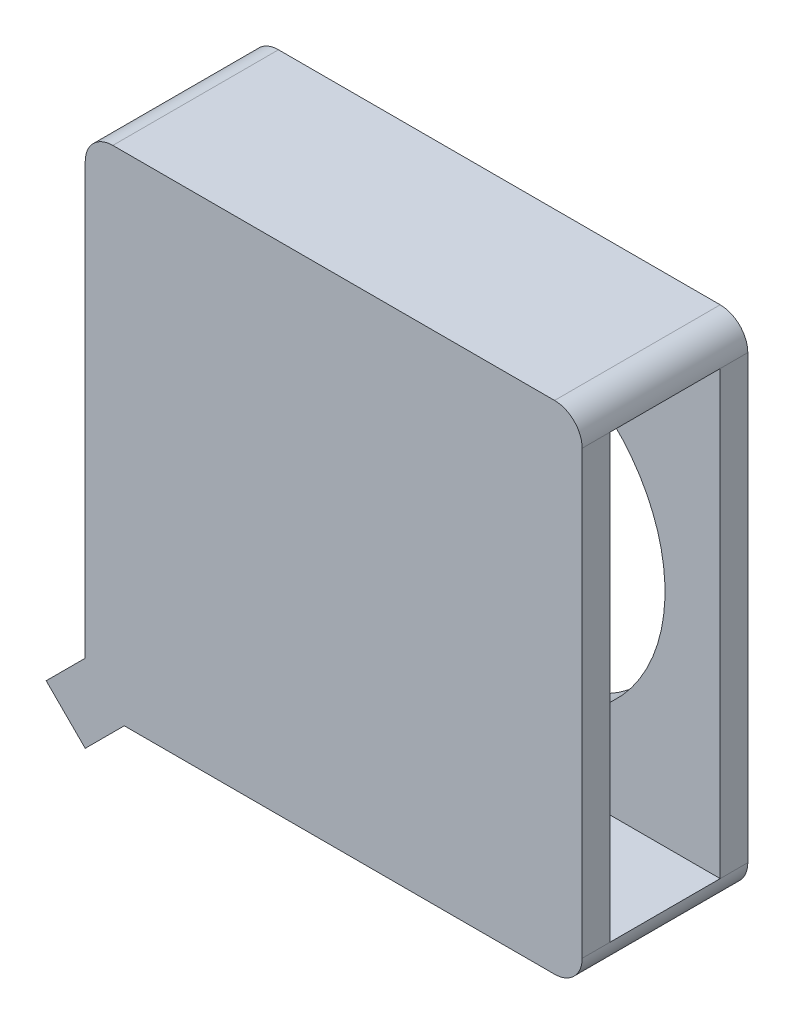
from build123d import *

# Parameters (mm, degrees)
SKETCH_1_W          = 9
SKETCH_1_H          = 9
EXTRUDE_1_DEPTH     = 3
FILLET_1_R          = 0.5
SKETCH_2_R          = 3
CUT_EXTRUDE_1_DEPTH = 2.5
SKETCH_3_W          = 2
SKETCH_3_H          = 8
CUT_EXTRUDE_2_DEPTH = 8.5
EXTRUDE_2_DEPTH     = 3


with BuildPart() as part:
    # 草图1 → 凸台-拉伸1 (new body)
    with BuildSketch(Plane.XY):
        with Locations((0.284053156, -1.823920266)):
            Rectangle(SKETCH_1_W, SKETCH_1_H)
    extrude(amount=EXTRUDE_1_DEPTH)

    # 圆角1
    fillet_1_edges = [part.edges().sort_by_distance(p)[0] for p in [
        (-4.215946844, 2.676079734, 1.5),
        (4.784053156, 2.676079734, 1.5),
        (4.784053156, -6.323920266, 1.5),
        (-4.215946844, -6.323920266, 1.5),
    ]]
    fillet(fillet_1_edges, radius=FILLET_1_R)

    # 草图2 → 切除-拉伸1 (cut)
    with BuildSketch(Plane(origin=(0, 0, 0), x_dir=(-1, 0, 0), z_dir=(0, 0, -1))):
        with Locations((-0.784053156, -1.823920266)):
            Circle(SKETCH_2_R)
    extrude(amount=-CUT_EXTRUDE_1_DEPTH, mode=Mode.SUBTRACT)

    # 草图3 → 切除-拉伸2 (cut)
    with BuildSketch(Plane(origin=(4.784053156, 0, 0), x_dir=(0, 0, -1), z_dir=(1, 0, 0))):
        with Locations((-1.5, -1.823920266)):
            Rectangle(SKETCH_3_W, SKETCH_3_H)
    extrude(amount=-CUT_EXTRUDE_2_DEPTH, mode=Mode.SUBTRACT)

    # 草图4 → 凸台-拉伸2 (add)
    with BuildSketch(Plane(origin=(0, 0, 0), x_dir=(-1, 0, 0), z_dir=(0, 0, -1))):
        Polygon((4.215946844, -5.616813485), (3.508840063, -6.323920266), (4.215946844, -7.031027047), (4.923053625, -6.323920266), align=None)
    extrude(amount=-EXTRUDE_2_DEPTH)


solid = part.part
